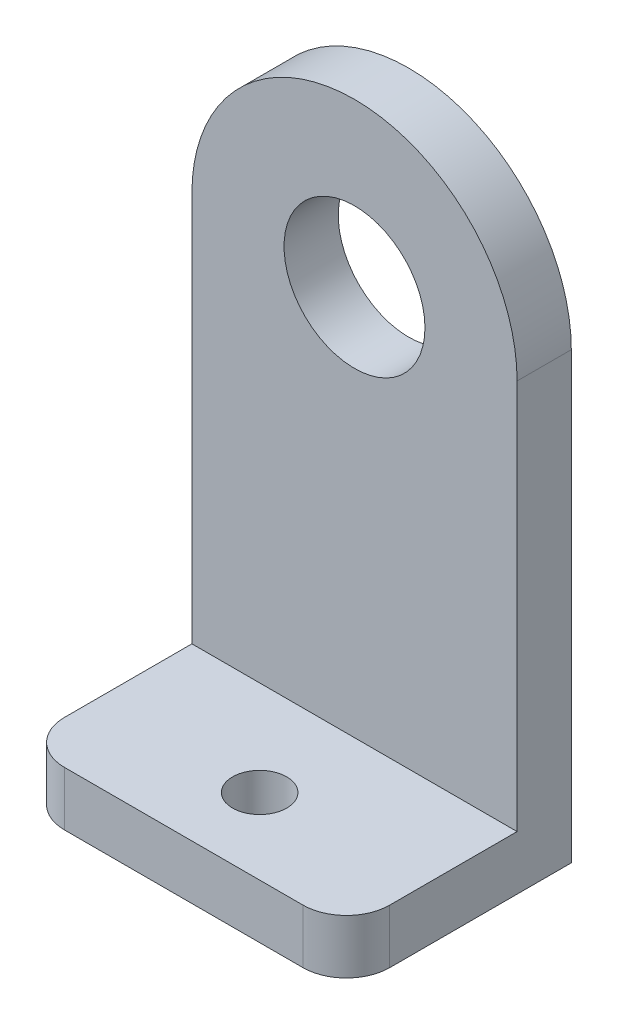
from build123d import *

# Parameters (mm, degrees)
BOSS_EXTRUDE1_DEPTH = 6.35
SKETCH2_W           = 38.1
SKETCH2_H           = 41.275
SKETCH2_R           = 3.175
BOSS_EXTRUDE2_DEPTH = 3.175
SKETCH4_W           = 38.1
SKETCH4_H           = 3.175
BOSS_EXTRUDE3_DEPTH = 2.54
SKETCH5_W           = 38.1
SKETCH5_H           = 46.355
BOSS_EXTRUDE4_DEPTH = 3.175
SKETCH6_R           = 3.175
CUT_EXTRUDE1_DEPTH  = 6.35
FILLET1_R           = 5.08
SKETCH7_W           = 70.311291794
SKETCH7_H           = 15.462980338
CUT_EXTRUDE2_DEPTH  = 20.0025


with BuildPart() as part:
    # Sketch1 → Boss-Extrude1 (new body)
    with BuildSketch(Plane.XY):
        with BuildLine():
            ThreePointArc((-8.255, 0), (0, 8.255), (8.255, 0))
            Line((8.255, 0), (19.05, 0))
            ThreePointArc((19.05, 0), (0, 19.05), (-19.05, 0))
            Line((-19.05, 0), (-8.255, 0))
        make_face()
        with BuildLine():
            Line((19.05, 0), (8.255, 0))
            ThreePointArc((8.255, 0), (0, -8.255), (-8.255, 0))
            Line((-8.255, 0), (-19.05, 0))
            ThreePointArc((-19.05, 0), (0, -19.05), (19.05, 0))
        make_face()
        with BuildLine():
            Line((19.05, -45.72), (19.05, 0))
            ThreePointArc((19.05, 0), (0, -19.05), (-19.05, 0))
            Line((-19.05, 0), (-19.05, -45.72))
            Line((-19.05, -45.72), (19.05, -45.72))
        make_face()
    extrude(amount=BOSS_EXTRUDE1_DEPTH)

    # Sketch2 → Boss-Extrude2 (add)
    with BuildSketch(Plane.XZ.offset(45.72)):
        with Locations((0, 3.175)):
            Rectangle(SKETCH2_W, SKETCH2_H)
        with Locations((0, 17.4625)):
            Circle(SKETCH2_R, mode=Mode.SUBTRACT)
        with Locations((0, -11.1125)):
            Circle(SKETCH2_R, mode=Mode.SUBTRACT)
    extrude(amount=BOSS_EXTRUDE2_DEPTH)

    # Sketch4 → Boss-Extrude3 (add)
    with BuildSketch(Plane.XY.offset(23.8125)):
        with Locations((0, -47.3075)):
            Rectangle(SKETCH4_W, SKETCH4_H)
    boss_extrude3 = extrude(amount=BOSS_EXTRUDE3_DEPTH)

    # Mirror1: Boss-Extrude3 across plane
    add(boss_extrude3.mirror(Plane.XY.offset(3.175)))

    # Sketch5 → Boss-Extrude4 (add)
    with BuildSketch(Plane.XZ.offset(48.895)):
        with Locations((0, 3.175)):
            Rectangle(SKETCH5_W, SKETCH5_H)
    extrude(amount=BOSS_EXTRUDE4_DEPTH)

    # Sketch6 → Cut-Extrude1 (cut)
    with BuildSketch(Plane(origin=(0, -45.72, 0), x_dir=(1, 0, 0), z_dir=(0, 1, 0))):
        with Locations((0, 11.1125)):
            Circle(SKETCH6_R)
    cut_extrude1 = extrude(amount=-CUT_EXTRUDE1_DEPTH, mode=Mode.SUBTRACT)

    # Mirror2: Cut-Extrude1 across plane
    add(cut_extrude1.mirror(Plane.XY.offset(3.175)), mode=Mode.SUBTRACT)

    # Fillet1
    fillet1_edges = [part.edges().sort_by_distance(p)[0] for p in [
        (19.05, -48.895, 26.3525),
        (-19.05, -48.895, 26.3525),
        (-19.05, -48.895, -20.0025),
        (19.05, -48.895, -20.0025),
    ]]
    fillet(fillet1_edges, radius=FILLET1_R)

    # Sketch7 → Cut-Extrude2 (cut)
    with BuildSketch(Plane(origin=(0, 0, -20.0025), x_dir=(-1, 0, 0), z_dir=(0, 0, -1))):
        with Locations((-1.046028379, -47.628881587)):
            Rectangle(SKETCH7_W, SKETCH7_H)
    extrude(amount=-CUT_EXTRUDE2_DEPTH, mode=Mode.SUBTRACT)


solid = part.part
